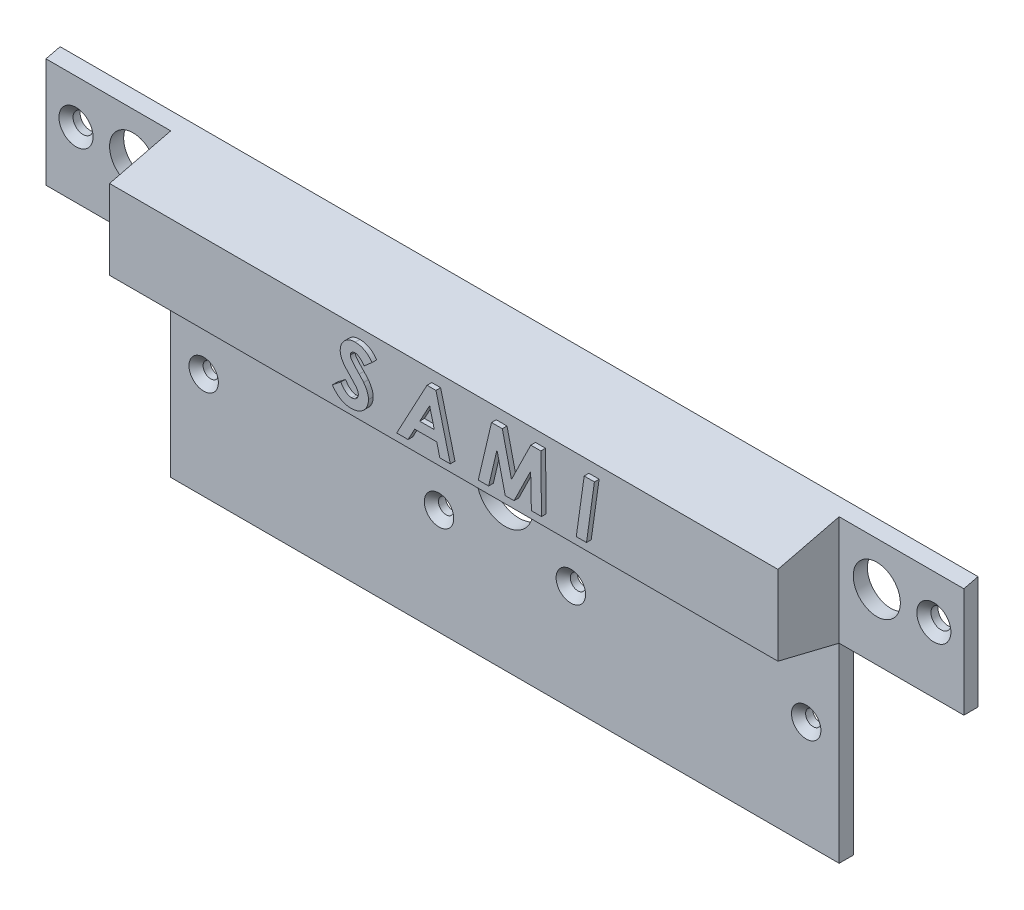
from build123d import *

# Parameters (mm, degrees)
CROQUIS1_R                 = 2.125
CROQUIS1_R_2               = 1.625
SALIENTE_EXTRUIR1_DEPTH    = 3
CROQUIS2_W                 = 142
CROQUIS2_H                 = 24
SALIENTE_EXTRUIR2_DEPTH    = 13
CORTAR_EXTRUIR1_START      = -4
CORTAR_EXTRUIR1_DEPTH      = 134
CORTAR_EXTRUIR2_DEPTH      = 27.5
CORTAR_EXTRUIR2_DEPTH_BACK = 169.5
SALIENTE_EXTRUIR3_DEPTH    = 1
CHAFL_N1_SIZE              = 1.5
CROQUIS7_R                 = 6
CORTAR_EXTRUIR3_DEPTH      = 10
CROQUIS11_R                = 5
CORTAR_EXTRUIR7_DEPTH      = 60


with BuildPart() as part:
    # Croquis1 → Saliente-Extruir1 (new body)
    with BuildSketch(Plane.XY):
        Polygon((-97.5, -2), (-97.5, -26), (-71, -26), (-71, -66.5), (71, -66.5), (71, -26), (97.5, -26), (97.5, -2), align=None)
        with Locations((-91.125, -12.1)):
            Circle(CROQUIS1_R, mode=Mode.SUBTRACT)
        with Locations((-64, -44)):
            Circle(CROQUIS1_R_2, mode=Mode.SUBTRACT)
        with Locations((-14, -44)):
            Circle(CROQUIS1_R_2, mode=Mode.SUBTRACT)
        with Locations((14, -44)):
            Circle(CROQUIS1_R_2, mode=Mode.SUBTRACT)
        with Locations((64, -44)):
            Circle(CROQUIS1_R_2, mode=Mode.SUBTRACT)
        with Locations((91.125, -12.1)):
            Circle(CROQUIS1_R, mode=Mode.SUBTRACT)
    extrude(amount=SALIENTE_EXTRUIR1_DEPTH)

    # Croquis2 → Saliente-Extruir2 (add)
    with BuildSketch(Plane.XY.offset(3)):
        with Locations((0, -14)):
            Rectangle(CROQUIS2_W, CROQUIS2_H)
    extrude(amount=SALIENTE_EXTRUIR2_DEPTH)

    # Croquis4 → Cortar-Extruir1 (cut)
    with BuildSketch(Plane.ZY.offset(71).offset(CORTAR_EXTRUIR1_START)):
        Polygon((0, -23), (12.254442441, -20), (12.254442441, -8), (0, -5), align=None)
    extrude(amount=-CORTAR_EXTRUIR1_DEPTH, mode=Mode.SUBTRACT)

    # Croquis5 → Cortar-Extruir2 (cut, two sides)
    with BuildSketch(Plane.ZY.offset(71)) as cortar_extruir2_sk:
        Polygon((3, -26), (16, -22.817480666), (16, -5.916946873), (0, -2), (13.126652557, 3.411104472), (22.490929508, -3.111277484), (22.490929508, -28.482984682), align=None)
    extrude(amount=CORTAR_EXTRUIR2_DEPTH, mode=Mode.SUBTRACT)
    extrude(cortar_extruir2_sk.sketch, amount=-CORTAR_EXTRUIR2_DEPTH_BACK, mode=Mode.SUBTRACT)

    # Croquis6 → Saliente-Extruir3 (add)
    with BuildSketch(Plane.XY.offset(16)):
        with BuildLine():
            Line((-14.237980769, -9.985749897), (-15.90625, -11.44007682))
            add(Edge.make_bspline(
                [(-15.90625, -11.44007682), (-15.989626138, -11.327448514), (-16.149414971, -11.111598441), (-16.40296706, -10.822085331), (-16.645879271, -10.570501926), (-16.890561991, -10.369874968), (-17.129057977, -10.210789404), (-17.363445534, -10.095551079), (-17.595042177, -10.022729498), (-17.749526692, -10.014017491), (-17.824519231, -10.009788358)],
                knots=[0, 0, 0, 0, 0.000420206, 0.000805317, 0.001153775, 0.001468027, 0.001752717, 0.00201182, 0.002249898, 0.0024745, 0.0024745, 0.0024745, 0.0024745], degree=3))
            add(Edge.make_bspline(
                [(-17.824519231, -10.009788358), (-17.895356089, -10.012855098), (-18.031584807, -10.018752848), (-18.22713207, -10.069034852), (-18.404858991, -10.149916554), (-18.557444672, -10.266921908), (-18.684884048, -10.401824243), (-18.779509513, -10.553209832), (-18.834618158, -10.720070113), (-18.842257012, -10.835512647), (-18.846153846, -10.894403743)],
                knots=[0, 0, 0, 0, 0.000212207, 0.000408102, 0.000601682, 0.00079399, 0.000981089, 0.001155893, 0.001325411, 0.001501943, 0.001501943, 0.001501943, 0.001501943], degree=3))
            add(Edge.make_bspline(
                [(-18.846153846, -10.894403743), (-18.842604913, -10.952419762), (-18.835140436, -11.074444962), (-18.780451752, -11.259433313), (-18.697727885, -11.454346792), (-18.598228785, -11.623824314), (-18.486512728, -11.77771519), (-18.369441299, -11.928296257), (-18.21657709, -12.108334434), (-18.030567158, -12.319891013), (-17.813188546, -12.564750981), (-17.558803159, -12.839351591), (-17.271991311, -13.145496303), (-17.068274685, -13.359303629), (-16.961538462, -13.47132682)],
                knots=[0, 0, 0, 0, 0.000173893, 0.000365749, 0.000574704, 0.000808471, 0.000953222, 0.001145079, 0.001380533, 0.001661618, 0.001990208, 0.002362773, 0.002784536, 0.003248728, 0.003248728, 0.003248728, 0.003248728], degree=3))
            add(Edge.make_bspline(
                [(-16.961538462, -13.47132682), (-16.903636795, -13.531223219), (-16.792534747, -13.646152772), (-16.636643855, -13.814003622), (-16.497508029, -13.969569485), (-16.369045391, -14.107401891), (-16.259073151, -14.234617568), (-16.165177608, -14.34816442), (-16.085465961, -14.446444683), (-16.0383396, -14.508090166), (-16.016826923, -14.536230666)],
                knots=[0, 0, 0, 0, 0.000249919, 0.000479546, 0.000687169, 0.000876036, 0.001044734, 0.001191546, 0.001318062, 0.001424322, 0.001424322, 0.001424322, 0.001424322], degree=3))
            add(Edge.make_bspline(
                [(-16.016826923, -14.536230666), (-15.931162119, -14.654577639), (-15.765940249, -14.88283367), (-15.551635213, -15.229880041), (-15.37438103, -15.564252574), (-15.235094927, -15.88990853), (-15.130899714, -16.210409792), (-15.05543423, -16.531054248), (-15.007896968, -16.854509011), (-15.002624572, -17.072130546), (-15, -17.180461435)],
                knots=[0, 0, 0, 0, 0.000438173, 0.000845105, 0.001222517, 0.001572563, 0.001906283, 0.002232223, 0.002559941, 0.00288478, 0.00288478, 0.00288478, 0.00288478], degree=3))
            add(Edge.make_bspline(
                [(-15, -17.180461435), (-15.003265975, -17.300028306), (-15.009693432, -17.535336508), (-15.059498325, -17.880577858), (-15.137073288, -18.211608952), (-15.252749328, -18.52644101), (-15.395580999, -18.828499955), (-15.576864744, -19.11336264), (-15.785408375, -19.385848928), (-16.026160027, -19.639521442), (-16.289666574, -19.871503798), (-16.576596067, -20.072392787), (-16.879880295, -20.243624017), (-17.202602308, -20.384593326), (-17.543778684, -20.491812043), (-17.90280078, -20.568073199), (-18.279005837, -20.61869508), (-18.536688597, -20.622983286), (-18.668269231, -20.625172973)],
                knots=[0, 0, 0, 0, 0.000358568, 0.000705664, 0.00104441, 0.001376706, 0.00171001, 0.002044827, 0.002387643, 0.002737945, 0.003092298, 0.003439094, 0.003786756, 0.004135545, 0.004493622, 0.004857612, 0.005235681, 0.005630176, 0.005630176, 0.005630176, 0.005630176], degree=3))
            add(Edge.make_bspline(
                [(-18.668269231, -20.625172973), (-18.769284127, -20.62314894), (-18.969252502, -20.619142179), (-19.265642237, -20.592539289), (-19.554845581, -20.547124694), (-19.836437535, -20.481588061), (-20.111006069, -20.399756263), (-20.378979241, -20.301531223), (-20.639686545, -20.182641261), (-20.893461855, -20.046177875), (-21.140328633, -19.891607359), (-21.378805584, -19.717085991), (-21.611465717, -19.525979253), (-21.835259605, -19.314667737), (-22.054912323, -19.088984376), (-22.266576688, -18.843795132), (-22.468125847, -18.578072355), (-22.596069502, -18.392506783), (-22.661057692, -18.298249897)],
                knots=[0, 0, 0, 0, 0.000303037, 0.00059989, 0.000891945, 0.001180587, 0.001466554, 0.001751001, 0.002036087, 0.002325399, 0.002614861, 0.002909123, 0.003211368, 0.003517498, 0.003831997, 0.00415583, 0.004488535, 0.004831982, 0.004831982, 0.004831982, 0.004831982], degree=3))
            Line((-22.661057692, -18.298249897), (-20.884615385, -16.901615281))
            add(Edge.make_bspline(
                [(-20.884615385, -16.901615281), (-20.796133427, -17.037667664), (-20.626430657, -17.298607485), (-20.34982297, -17.650830005), (-20.067822589, -17.950179859), (-19.779405576, -18.195493135), (-19.483644037, -18.386365741), (-19.182661042, -18.522803011), (-18.875117063, -18.610559253), (-18.666427793, -18.620314724), (-18.5625, -18.625172973)],
                knots=[0, 0, 0, 0, 0.0004867, 0.00093346, 0.001341534, 0.00171857, 0.002066655, 0.002393719, 0.002707437, 0.003018659, 0.003018659, 0.003018659, 0.003018659], degree=3))
            add(Edge.make_bspline(
                [(-18.5625, -18.625172973), (-18.466608696, -18.620970508), (-18.279938128, -18.612789613), (-18.012906753, -18.536619842), (-17.767915589, -18.419199206), (-17.555817127, -18.251540983), (-17.377139034, -18.054637597), (-17.24725602, -17.83032248), (-17.169063266, -17.584546429), (-17.158994702, -17.414201651), (-17.153846154, -17.32709605)],
                knots=[0, 0, 0, 0, 0.000287066, 0.000558828, 0.00082652, 0.001097228, 0.001364531, 0.001619757, 0.001869133, 0.002130091, 0.002130091, 0.002130091, 0.002130091], degree=3))
            add(Edge.make_bspline(
                [(-17.153846154, -17.32709605), (-17.156305742, -17.256296592), (-17.161308997, -17.11227744), (-17.213463163, -16.897776687), (-17.290868572, -16.680273894), (-17.384686199, -16.496451163), (-17.485874595, -16.335262812), (-17.593034102, -16.189295342), (-17.727871488, -16.01796368), (-17.894684288, -15.825289294), (-18.086653682, -15.6047675), (-18.311053405, -15.364148452), (-18.560713769, -15.095469359), (-18.739972106, -14.911640288), (-18.834134615, -14.81507682)],
                knots=[0, 0, 0, 0, 0.00021203, 0.000431307, 0.000658658, 0.000903768, 0.001048499, 0.001229299, 0.001446671, 0.001702452, 0.001993715, 0.002323752, 0.002689397, 0.003094001, 0.003094001, 0.003094001, 0.003094001], degree=3))
            add(Edge.make_bspline(
                [(-18.834134615, -14.81507682), (-18.933796083, -14.712000384), (-19.126457636, -14.512737151), (-19.399022138, -14.221116735), (-19.644537968, -13.949692255), (-19.862727128, -13.698178106), (-20.053769849, -13.466122167), (-20.220971836, -13.255284863), (-20.359272385, -13.062884941), (-20.43727304, -12.93805128), (-20.473557692, -12.879980666)],
                knots=[0, 0, 0, 0, 0.000430127, 0.000831505, 0.001197435, 0.001528049, 0.001830294, 0.002099105, 0.002335234, 0.002540618, 0.002540618, 0.002540618, 0.002540618], degree=3))
            add(Edge.make_bspline(
                [(-20.473557692, -12.879980666), (-20.554574406, -12.735277508), (-20.711760817, -12.454528401), (-20.873808353, -12.012655576), (-20.979408373, -11.576459651), (-20.993212918, -11.285199559), (-21, -11.141999897)],
                knots=[0, 0, 0, 0, 0.000496759, 0.000963799, 0.001407574, 0.00183678, 0.00183678, 0.00183678, 0.00183678], degree=3))
            add(Edge.make_bspline(
                [(-21, -11.141999897), (-20.997562984, -11.049741664), (-20.992715305, -10.866222803), (-20.957815751, -10.595373109), (-20.904379157, -10.330523561), (-20.819192416, -10.075691466), (-20.720947532, -9.824495817), (-20.592529271, -9.583537033), (-20.448250884, -9.34633255), (-20.332500788, -9.199389859), (-20.274038462, -9.125172973)],
                knots=[0, 0, 0, 0, 0.000276703, 0.000550415, 0.000818204, 0.001085798, 0.001355415, 0.001626358, 0.001903843, 0.002187018, 0.002187018, 0.002187018, 0.002187018], degree=3))
            add(Edge.make_bspline(
                [(-20.274038462, -9.125172973), (-20.196863127, -9.035727326), (-20.044645553, -8.859308275), (-19.781280254, -8.633794587), (-19.502039805, -8.439002065), (-19.200913405, -8.282622933), (-18.881363751, -8.157986947), (-18.54035169, -8.073413083), (-18.180490688, -8.018161336), (-17.933706603, -8.012618614), (-17.807692308, -8.009788358)],
                knots=[0, 0, 0, 0, 0.000353962, 0.00069814, 0.001036869, 0.001373416, 0.001713584, 0.002063399, 0.002425456, 0.002803234, 0.002803234, 0.002803234, 0.002803234], degree=3))
            add(Edge.make_bspline(
                [(-17.807692308, -8.009788358), (-17.633433825, -8.01587198), (-17.289683468, -8.027872813), (-16.783975681, -8.121148963), (-16.302065667, -8.279260008), (-15.839133772, -8.494079527), (-15.402696524, -8.776984417), (-14.986925157, -9.11896429), (-14.592049103, -9.522456693), (-14.358202489, -9.828441546), (-14.237980769, -9.985749897)],
                knots=[0, 0, 0, 0, 0.00052257, 0.001030845, 0.001536368, 0.002040723, 0.002557506, 0.003092139, 0.003653106, 0.004246642, 0.004246642, 0.004246642, 0.004246642], degree=3))
        make_face()
        Polygon((-2.550480769, -8.317480666), (-0.661057692, -8.317480666), (2.384615385, -20.317480666), (0.168269231, -20.317480666), (-0.495192308, -17.70209605), (-5.173076923, -17.70209605), (-6.576923077, -20.317480666), (-9, -20.317480666), align=None)
        Polygon((-1.007211538, -15.70209605), (-1.997596154, -11.79584605), (-4.096153846, -15.70209605), align=None, mode=Mode.SUBTRACT)
        Polygon((11.149038462, -8.317480666), (13.439903846, -8.317480666), (15.384615385, -16.678057589), (19.490384615, -8.317480666), (21.615384615, -8.317480666), (21.769230769, -20.317480666), (19.615384615, -20.317480666), (19.461538462, -13.13959605), (15.9375, -20.317480666), (14.060096154, -20.317480666), (12.307692308, -12.779019127), (10.536057692, -20.317480666), (8.329326923, -20.317480666), align=None)
        Polygon((30.836538462, -8.317480666), (33.009615385, -8.317480666), (31.326923077, -20.317480666), (29.153846154, -20.317480666), align=None)
    extrude(amount=SALIENTE_EXTRUIR3_DEPTH)

    # Chaflán1
    chafl_n1_edges = [part.edges().sort_by_distance(p)[0] for p in [
        (-93.25, -12.1, 3),
        (-65.625, -44, 3),
        (-15.625, -44, 3),
        (12.375, -44, 3),
        (62.375, -44, 3),
        (89, -12.1, 3),
    ]]
    chamfer(chafl_n1_edges, length=CHAFL_N1_SIZE)

    # Croquis7 → Cortar-Extruir3 (cut)
    with BuildSketch(Plane.XY.offset(3)):
        with Locations((0, -34)):
            Circle(CROQUIS7_R)
    extrude(amount=-CORTAR_EXTRUIR3_DEPTH, mode=Mode.SUBTRACT)

    # Croquis11 → Cortar-Extruir7 (cut)
    with BuildSketch(Plane.XY.offset(3)):
        with Locations((-79, -12.1)):
            Circle(CROQUIS11_R)
        with Locations((79, -12.1)):
            Circle(CROQUIS11_R)
    extrude(amount=-CORTAR_EXTRUIR7_DEPTH, mode=Mode.SUBTRACT)


solid = part.part
